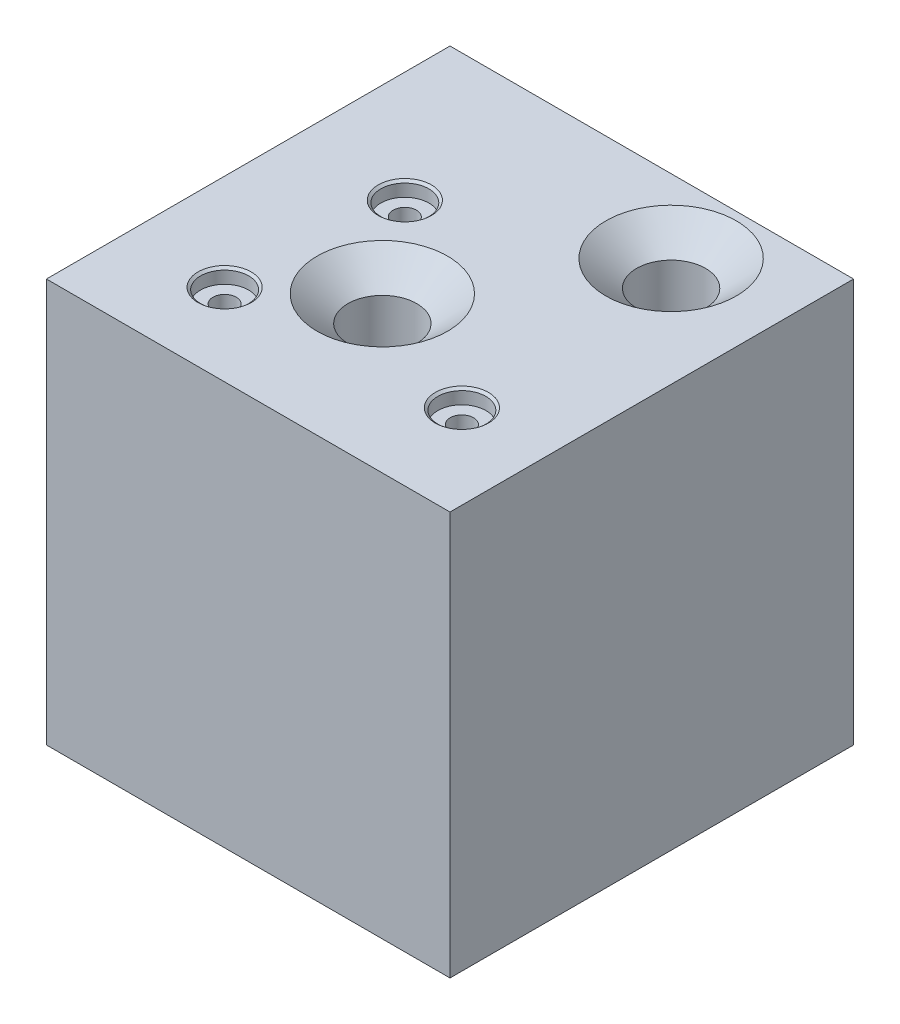
from build123d import *

# Parameters (mm, degrees)
SKETCH1_W                                       = 100
SKETCH1_H                                       = 100
BOSS_EXTRUDE1_DEPTH                             = 50
CSK_FOR_M2_FLAT_HEAD_MACHINE_SCREW1_D           = 17.07
CSK_FOR_M2_FLAT_HEAD_MACHINE_SCREW1_DEPTH       = 50.8
CSK_FOR_M2_FLAT_HEAD_MACHINE_SCREW1_CSINK_D     = 32.31
CSK_FOR_M2_FLAT_HEAD_MACHINE_SCREW1_CSINK_ANGLE = 100
CSK_FOR_M2_FLAT_HEAD_MACHINE_SCREW1_TIP         = 5.128345383
CBORE_FOR_M5_HEX_HEAD_BOLT1_AT_2_COUNT          = 2
CBORE_FOR_M5_HEX_HEAD_BOLT1_AT_2_PITCH          = 41.165028735
CBORE_FOR_M5_HEX_HEAD_BOLT1_AT_3_COUNT          = 2
CBORE_FOR_M5_HEX_HEAD_BOLT1_AT_3_PITCH          = 63.773894401


with BuildPart() as part:
    # Sketch1 → Boss-Extrude1 (new body, symmetric)
    with BuildSketch(Plane(origin=(0, 0, 0), x_dir=(1, 0, 0), z_dir=(0, 1, 0))):
        Rectangle(SKETCH1_W, SKETCH1_H)
    extrude(amount=BOSS_EXTRUDE1_DEPTH, both=True)

    # CSK for M2 Flat Head Machine Screw1
    with Locations(Plane(origin=(0, 50, 0), x_dir=(1, 0, 0), z_dir=(0, 1, 0))):
        with Locations((22.975631471, 31.812412806), (-5.231547771, -11.532234815)):
            CounterSinkHole(CSK_FOR_M2_FLAT_HEAD_MACHINE_SCREW1_D / 2, CSK_FOR_M2_FLAT_HEAD_MACHINE_SCREW1_CSINK_D / 2, depth=CSK_FOR_M2_FLAT_HEAD_MACHINE_SCREW1_DEPTH, counter_sink_angle=CSK_FOR_M2_FLAT_HEAD_MACHINE_SCREW1_CSINK_ANGLE)
            with Locations((0, 0, -(CSK_FOR_M2_FLAT_HEAD_MACHINE_SCREW1_DEPTH + CSK_FOR_M2_FLAT_HEAD_MACHINE_SCREW1_TIP / 2))):  # 118° drill point
                Cone(0, CSK_FOR_M2_FLAT_HEAD_MACHINE_SCREW1_D / 2, CSK_FOR_M2_FLAT_HEAD_MACHINE_SCREW1_TIP, mode=Mode.SUBTRACT)

    # Sketch10 → CBORE for M5 Hex Head Bolt1 (revolve, cut)
    with BuildSketch(Plane(origin=(-22.504336466, 50, -11.311080109), x_dir=(0, 0, 1), z_dir=(1, 0, 0))):
        Polygon((0, 0), (0, 100), (2.895, 100), (2.895, 3.58), (5.955, 3.58), (5.955, 0.532828266), (6.59, 0), align=None)
    cbore_for_m5_hex_head_bolt1 = revolve(axis=Axis((-22.504336466, 56.35, -11.311080109), (0, -1, 0)), mode=Mode.SUBTRACT)

    # CBORE for M5 Hex Head Bolt1 at 2: CBORE for M5 Hex Head Bolt1 ×2
    with Locations(*[Vector(-0.088729108, 0, 0.996055794) * (i * CBORE_FOR_M5_HEX_HEAD_BOLT1_AT_2_PITCH) for i in range(1, CBORE_FOR_M5_HEX_HEAD_BOLT1_AT_2_COUNT)]):
        add(cbore_for_m5_hex_head_bolt1, mode=Mode.SUBTRACT)

    # CBORE for M5 Hex Head Bolt1 at 3: CBORE for M5 Hex Head Bolt1 ×2
    with Locations(*[Vector(0.809215173, 0, 0.587512386) * (i * CBORE_FOR_M5_HEX_HEAD_BOLT1_AT_3_PITCH) for i in range(1, CBORE_FOR_M5_HEX_HEAD_BOLT1_AT_3_COUNT)]):
        add(cbore_for_m5_hex_head_bolt1, mode=Mode.SUBTRACT)


solid = part.part
